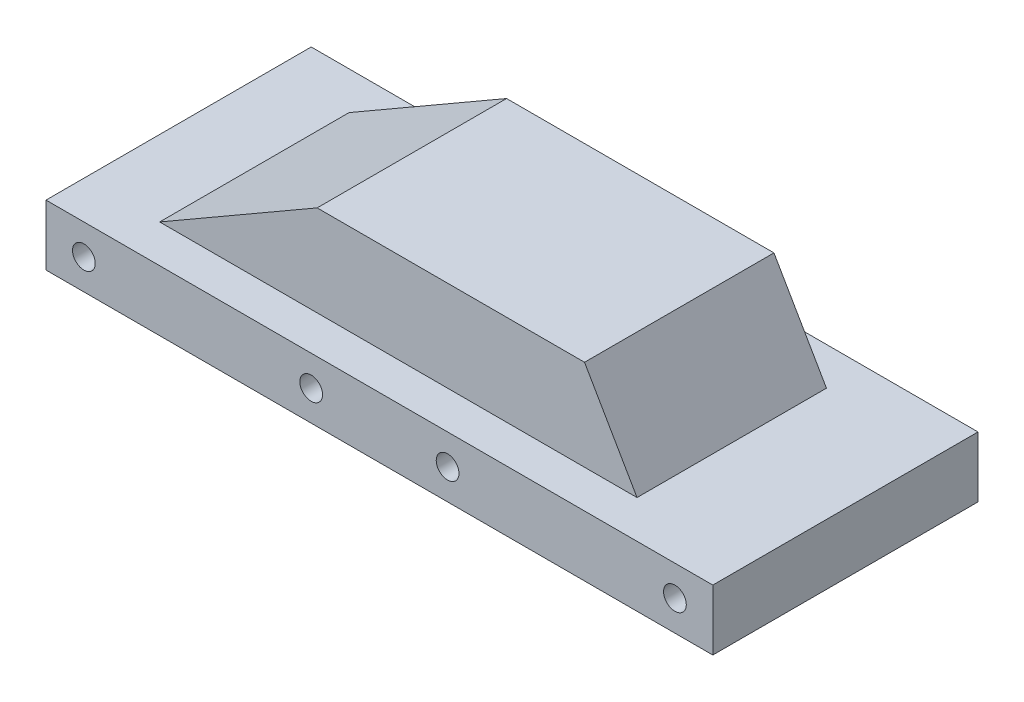
from build123d import *

# Parameters (mm, degrees)
EXTRUDE_1_DEPTH      = 4
EXTRUDE_1_DEPTH_BACK = 4
SKETCH_1_W           = 88
SKETCH_1_H           = 35
SKETCH_2_R           = 1.5
CUT_EXTRUDE_1_DEPTH  = 57.364882684
EXTRUDE_2_DEPTH      = 12.5


with BuildPart() as part:
    # 草图1 → 凸台-拉伸1 (new, two sides: drawn at the far end of the back side and taken through both)
    with BuildSketch(Plane(origin=(0, 0, 0), x_dir=(1, 0, 0), z_dir=(0, 1, 0)).offset(-EXTRUDE_1_DEPTH_BACK)):
        Rectangle(SKETCH_1_W, SKETCH_1_H)
    extrude(amount=EXTRUDE_1_DEPTH + EXTRUDE_1_DEPTH_BACK)

    # 草图2 → 切除-拉伸1 (cut, through all)
    with BuildSketch(Plane(origin=(0, 0, -17.5), x_dir=(-1, 0, 0), z_dir=(0, 0, -1))):
        with Locations((39, 0)):
            Circle(SKETCH_2_R)
        with Locations((-39, 0)):
            Circle(SKETCH_2_R)
        with Locations((-9, 0)):
            Circle(SKETCH_2_R)
        with Locations((9, 0)):
            Circle(SKETCH_2_R)
    extrude(amount=-CUT_EXTRUDE_1_DEPTH, mode=Mode.SUBTRACT)

    # 草图3 → 凸台-拉伸2 (add, symmetric)
    with BuildSketch(Plane.XY):
        Polygon((29, 4), (22.07179677, 16), (-13.215390309, 16), (-34, 4), align=None)
    extrude(amount=EXTRUDE_2_DEPTH, both=True)


solid = part.part
